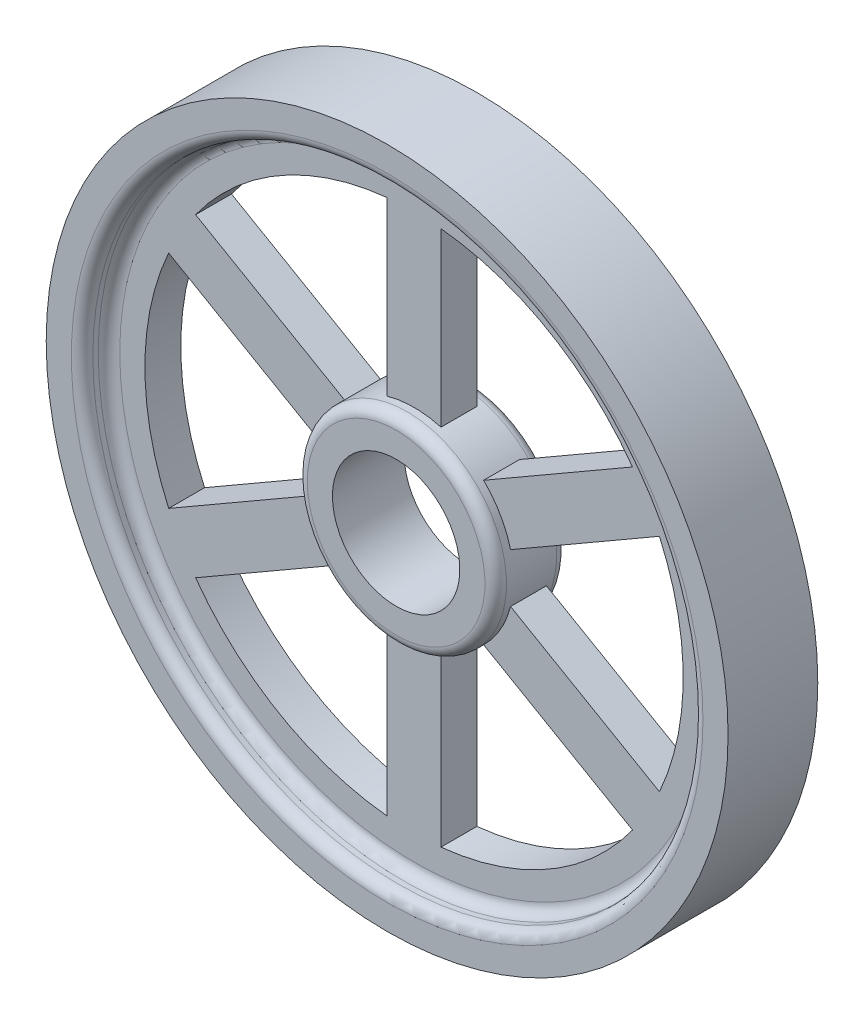
from build123d import *

# Parameters (mm, degrees)
SKETCH2_R                = 95
SKETCH2_R_2              = 85
BOSS_EXTRUDE1_DEPTH      = 25
SKETCH5_R                = 27.75
SKETCH5_R_2              = 17.75
BOSS_EXTRUDE2_DEPTH      = 10
BOSS_EXTRUDE2_DEPTH_BACK = 10
FILLET3_R                = 3
SKETCH7_R                = 85
SKETCH7_R_2              = 75
BOSS_EXTRUDE4_DEPTH      = 5
BOSS_EXTRUDE4_DEPTH_BACK = 5
BOSS_EXTRUDE5_DEPTH      = 5
FILLET4_R                = 3
FILLET8_R                = 3
FILLET9_R                = 3
CIRPATTERN2_COUNT        = 6


with BuildPart() as part:
    # Sketch2 → Boss-Extrude1 (new body)
    with BuildSketch(Plane.XY):
        Circle(SKETCH2_R)
        Circle(SKETCH2_R_2, mode=Mode.SUBTRACT)
    extrude(amount=BOSS_EXTRUDE1_DEPTH)

    # Sketch7 → Boss-Extrude4 (add, two sides)
    with BuildSketch(Plane(origin=(0, 0, 12.5), x_dir=(-1, 0, 0), z_dir=(0, 0, -1))) as boss_extrude4_sk:
        Circle(SKETCH7_R)
        Circle(SKETCH7_R_2, mode=Mode.SUBTRACT)
    extrude(amount=BOSS_EXTRUDE4_DEPTH)
    extrude(boss_extrude4_sk.sketch, amount=-BOSS_EXTRUDE4_DEPTH_BACK)



with BuildPart() as body_2:
    # Sketch5 → Boss-Extrude2 (new body, two sides)
    with BuildSketch(Plane(origin=(0, 0, 12.5), x_dir=(-1, 0, 0), z_dir=(0, 0, -1))) as boss_extrude2_sk:
        Circle(SKETCH5_R)
        Circle(SKETCH5_R_2, mode=Mode.SUBTRACT)
    extrude(amount=BOSS_EXTRUDE2_DEPTH)
    extrude(boss_extrude2_sk.sketch, amount=-BOSS_EXTRUDE2_DEPTH_BACK)

    # Fillet3
    fillet3_edges = [body_2.edges().sort_by_distance(p)[0] for p in [
        (27.75, 0, 22.5),
        (27.75, 0, 2.5),
    ]]
    fillet(fillet3_edges, radius=FILLET3_R)


with BuildPart() as part_1:
    add(part.part)

    add(body_2.part)  # Boss-Extrude5 merges body 2
    # Sketch9 → Boss-Extrude5 (add, symmetric)
    with BuildSketch(Plane(origin=(0, 0, 12.5), x_dir=(-1, 0, 0), z_dir=(0, 0, -1))):
        with BuildLine():
            Line((7.5, 26.717269696), (7.5, 74.624057783))
            ThreePointArc((7.5, 74.624057783), (0, 75), (-7.5, 74.624057783))
            Line((-7.5, 74.624057783), (-7.5, 26.717269696))
            ThreePointArc((-7.5, 26.717269696), (0, 27.75), (7.5, 26.717269696))
        make_face()
    boss_extrude5 = extrude(amount=BOSS_EXTRUDE5_DEPTH, both=True)

    # Fillet4
    fillet4_edges = [part_1.edges().sort_by_distance(p)[0] for p in [
        (-85, 0, 25),
    ]]
    fillet(fillet4_edges, radius=FILLET4_R)

    # Fillet8
    fillet8_edges = [part_1.edges().sort_by_distance(p)[0] for p in [
        (-85, 0, 0),
    ]]
    fillet(fillet8_edges, radius=FILLET8_R)

    # Fillet9
    fillet9_edges = [part_1.edges().sort_by_distance(p)[0] for p in [
        (-85, 0, 17.5),
        (-85, 0, 7.5),
    ]]
    fillet(fillet9_edges, radius=FILLET9_R)

    # CirPattern2: Boss-Extrude5 ×6 about axis
    cirpattern2_axis = Axis((0, 0, 0), (0, 0, 1))
    for i in range(1, CIRPATTERN2_COUNT):
        add(boss_extrude5.rotate(cirpattern2_axis, i * 360 / CIRPATTERN2_COUNT))


solid = part_1.part
